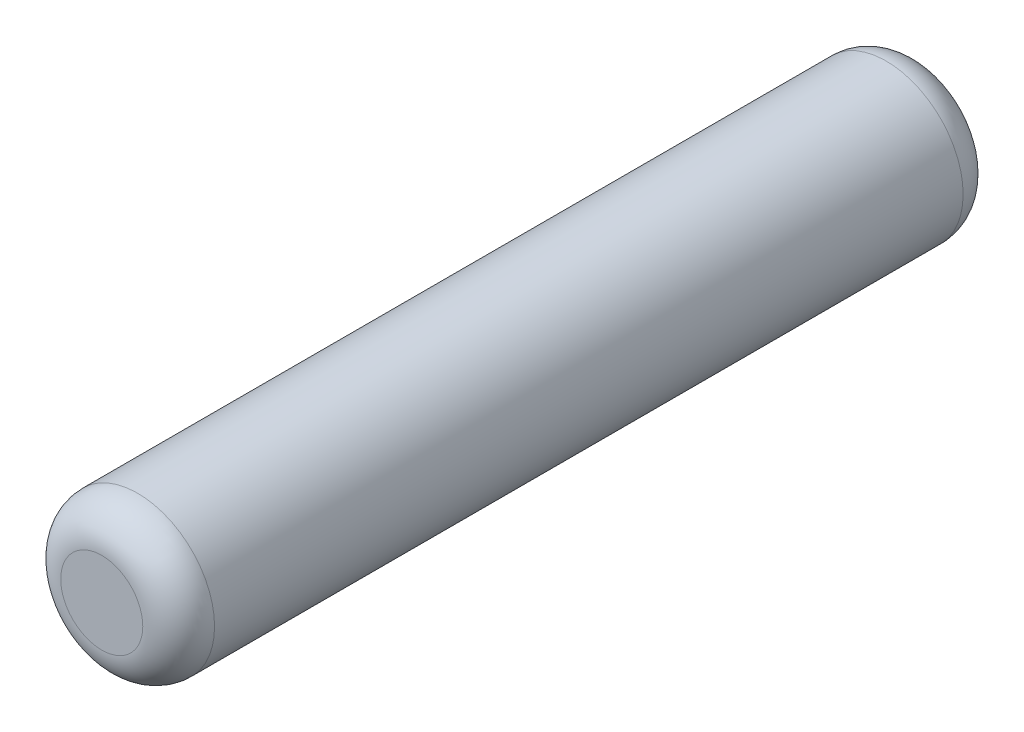
from build123d import *

# Parameters (mm, degrees)
SKETCH1_R           = 0.75
BOSS_EXTRUDE1_DEPTH = 4
FILLET1_R           = 0.35


with BuildPart() as part:
    # Sketch1 → Boss-Extrude1 (new body, symmetric)
    with BuildSketch(Plane.XY):
        Circle(SKETCH1_R)
    extrude(amount=BOSS_EXTRUDE1_DEPTH, both=True)

    # Fillet1
    fillet1_edges = [part.edges().sort_by_distance(p)[0] for p in [
        (-0.75, 0, -4),
        (-0.75, 0, 4),
    ]]
    fillet(fillet1_edges, radius=FILLET1_R)


solid = part.part
